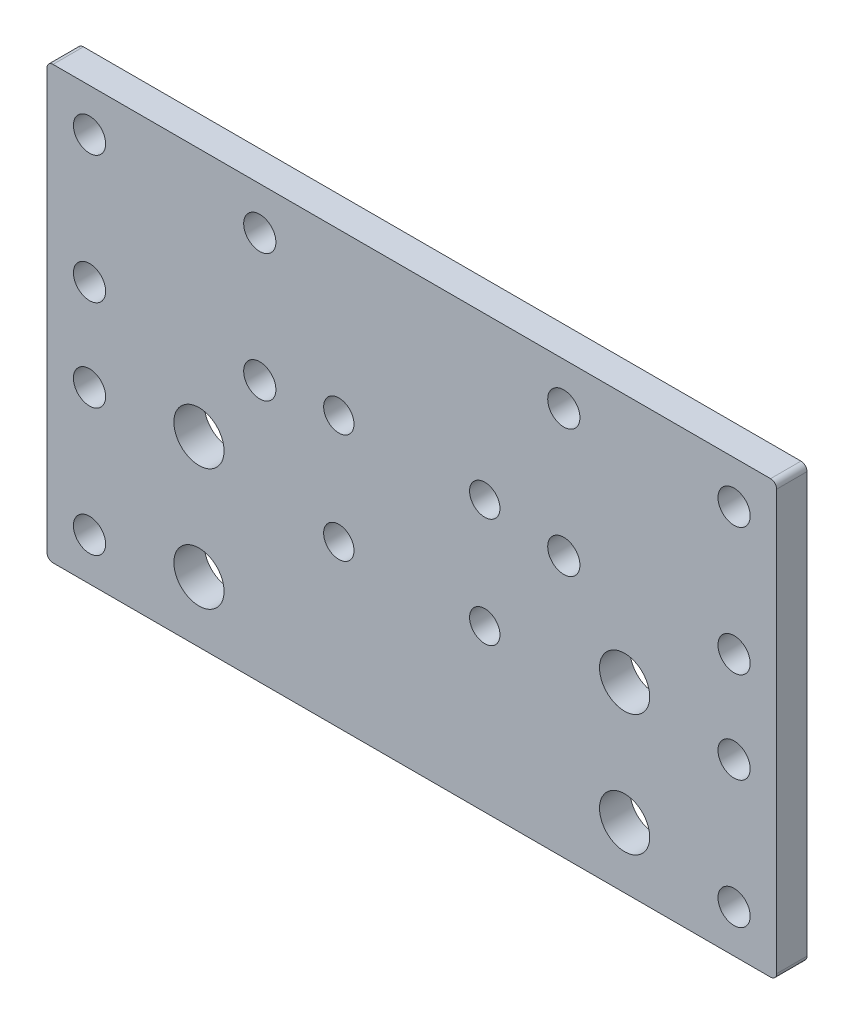
from build123d import *

# Parameters (mm, degrees)
SKETCH1_W               = 120
SKETCH1_H               = 71
SKETCH1_R               = 2.5
BOSS_EXTRUDE1_DEPTH     = 5
FILLET1_R               = 1
SKETCH3_R               = 2.65
SKETCH3_R_2             = 4.1275
CUT_EXTRUDE1_DEPTH      = 39
CUT_EXTRUDE1_DEPTH_BACK = 46


with BuildPart() as part:
    # Sketch1 → Boss-Extrude1 (new body)
    with BuildSketch(Plane.XY):
        with Locations((60, 35.5)):
            Rectangle(SKETCH1_W, SKETCH1_H)
        with Locations((48, 44.5)):
            Circle(SKETCH1_R, mode=Mode.SUBTRACT)
        with Locations((72, 44.5)):
            Circle(SKETCH1_R, mode=Mode.SUBTRACT)
        with Locations((48, 26.5)):
            Circle(SKETCH1_R, mode=Mode.SUBTRACT)
        with Locations((72, 26.5)):
            Circle(SKETCH1_R, mode=Mode.SUBTRACT)
    extrude(amount=BOSS_EXTRUDE1_DEPTH)

    # Fillet1
    fillet1_edges = [part.edges().sort_by_distance(p)[0] for p in [
        (0, 71, 2.5),
        (120, 71, 2.5),
        (120, 0, 2.5),
        (0, 0, 2.5),
    ]]
    fillet(fillet1_edges, radius=FILLET1_R)

    # Sketch3 → Cut-Extrude1 (cut, two sides)
    with BuildSketch(Plane(origin=(0, 0, 0), x_dir=(-1, 0, 0), z_dir=(0, 0, -1))) as cut_extrude1_sk:
        with Locations((-113, 64)):
            Circle(SKETCH3_R)
        with Locations((-113, 43)):
            Circle(SKETCH3_R)
        with Locations((-85, 64)):
            Circle(SKETCH3_R)
        with Locations((-113, 28)):
            Circle(SKETCH3_R)
        with Locations((-113, 7)):
            Circle(SKETCH3_R)
        with Locations((-7, 7)):
            Circle(SKETCH3_R)
        with Locations((-7, 28)):
            Circle(SKETCH3_R)
        with Locations((-7, 64)):
            Circle(SKETCH3_R)
        with Locations((-7, 43)):
            Circle(SKETCH3_R)
        with Locations((-35, 64)):
            Circle(SKETCH3_R)
        with Locations((-35, 43)):
            Circle(SKETCH3_R)
        with Locations((-85, 43)):
            Circle(SKETCH3_R)
        with Locations((-25, 30)):
            Circle(SKETCH3_R_2)
        with Locations((-25, 10)):
            Circle(SKETCH3_R_2)
        with Locations((-95, 10)):
            Circle(SKETCH3_R_2)
        with Locations((-95, 30)):
            Circle(SKETCH3_R_2)
    extrude(amount=CUT_EXTRUDE1_DEPTH, mode=Mode.SUBTRACT)
    extrude(cut_extrude1_sk.sketch, amount=-CUT_EXTRUDE1_DEPTH_BACK, mode=Mode.SUBTRACT)


solid = part.part
